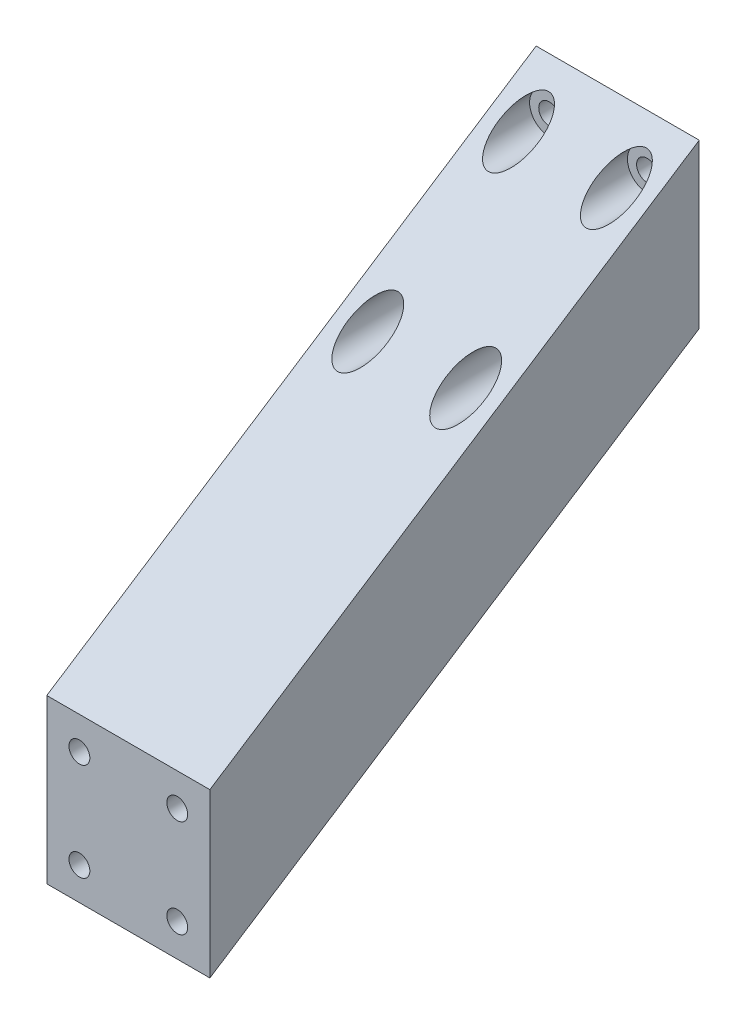
from build123d import *

# Parameters (mm, degrees)
BOSS_EXTRUDE1_DEPTH = 25
CUT_EXTRUDE7_REACH  = 97.856
CUT_EXTRUDE7_START  = -3
SKETCH3_R           = 3
SKETCH3_R_2         = 1.6
CUT_EXTRUDE8_REACH  = 94.856
SKETCH3_3_R         = 1.6
CUT_EXTRUDE9_REACH  = 97.856
CUT_EXTRUDE9_START  = -3
SKETCH4_R           = 3
SKETCH4_R_2         = 1.6
CUT_EXTRUDE10_REACH = 94.856
SKETCH4_2_R         = 1.6


with BuildPart() as part:
    # Sketch1 → Boss-Extrude1 (new body)
    with BuildSketch(Plane(origin=(0, 0, 0), x_dir=(0, 0, -1), z_dir=(1, 0, 0))):
        Polygon((0, 0), (-75, -48.70556949), (-75, -23.70556949), (0, 25), align=None)
    extrude(amount=BOSS_EXTRUDE1_DEPTH)

    # Sketch3 → Cut-Extrude7 (cut, up to next)
    with BuildSketch(Plane(origin=(0, 0, 0), x_dir=(-1, 0, 0), z_dir=(0, 0, -1)).offset(CUT_EXTRUDE7_START), mode=Mode.PRIVATE) as cut_extrude7_sk1:
        with Locations((-20, 20)):
            Circle(SKETCH3_R)
        with Locations((-20, 20)):
            Circle(SKETCH3_R_2, mode=Mode.SUBTRACT)
    cut_extrude7_tool1 = extrude(cut_extrude7_sk1.sketch, amount=-CUT_EXTRUDE7_REACH, mode=Mode.PRIVATE) & part.part
    # Sketch3 → Cut-Extrude7 (cut, up to next)
    with BuildSketch(Plane(origin=(0, 0, 0), x_dir=(-1, 0, 0), z_dir=(0, 0, -1)).offset(CUT_EXTRUDE7_START), mode=Mode.PRIVATE) as cut_extrude7_sk2:
        with Locations((-20, 5)):
            Circle(SKETCH3_R)
        with Locations((-20, 5)):
            Circle(SKETCH3_R_2, mode=Mode.SUBTRACT)
    cut_extrude7_tool2 = extrude(cut_extrude7_sk2.sketch, amount=-CUT_EXTRUDE7_REACH, mode=Mode.PRIVATE) & part.part
    # Sketch3 → Cut-Extrude7 (cut, up to next)
    with BuildSketch(Plane(origin=(0, 0, 0), x_dir=(-1, 0, 0), z_dir=(0, 0, -1)).offset(CUT_EXTRUDE7_START), mode=Mode.PRIVATE) as cut_extrude7_sk3:
        with Locations((-5, 5)):
            Circle(SKETCH3_R)
        with Locations((-5, 5)):
            Circle(SKETCH3_R_2, mode=Mode.SUBTRACT)
    cut_extrude7_tool3 = extrude(cut_extrude7_sk3.sketch, amount=-CUT_EXTRUDE7_REACH, mode=Mode.PRIVATE) & part.part
    # Sketch3 → Cut-Extrude7 (cut, up to next)
    with BuildSketch(Plane(origin=(0, 0, 0), x_dir=(-1, 0, 0), z_dir=(0, 0, -1)).offset(CUT_EXTRUDE7_START), mode=Mode.PRIVATE) as cut_extrude7_sk4:
        with Locations((-5, 20)):
            Circle(SKETCH3_R)
        with Locations((-5, 20)):
            Circle(SKETCH3_R_2, mode=Mode.SUBTRACT)
    cut_extrude7_tool4 = extrude(cut_extrude7_sk4.sketch, amount=-CUT_EXTRUDE7_REACH, mode=Mode.PRIVATE) & part.part
    add(cut_extrude7_tool1.solids().sort_by_distance((22.915147, 20, 3))[0], mode=Mode.SUBTRACT)
    add(cut_extrude7_tool2.solids().sort_by_distance((22.915147, 5, 3))[0], mode=Mode.SUBTRACT)
    add(cut_extrude7_tool3.solids().sort_by_distance((7.915147, 5, 3))[0], mode=Mode.SUBTRACT)
    add(cut_extrude7_tool4.solids().sort_by_distance((7.915147, 20, 3))[0], mode=Mode.SUBTRACT)

    # Sketch3_3 → Cut-Extrude8 (cut, up to next)
    with BuildSketch(Plane(origin=(0, 0, 0), x_dir=(-1, 0, 0), z_dir=(0, 0, -1)), mode=Mode.PRIVATE) as cut_extrude8_sk1:
        with Locations((-20, 20)):
            Circle(SKETCH3_3_R)
    cut_extrude8_tool1 = extrude(cut_extrude8_sk1.sketch, amount=-CUT_EXTRUDE8_REACH, mode=Mode.PRIVATE) & part.part
    # Sketch3_3 → Cut-Extrude8 (cut, up to next)
    with BuildSketch(Plane(origin=(0, 0, 0), x_dir=(-1, 0, 0), z_dir=(0, 0, -1)), mode=Mode.PRIVATE) as cut_extrude8_sk2:
        with Locations((-20, 5)):
            Circle(SKETCH3_3_R)
    cut_extrude8_tool2 = extrude(cut_extrude8_sk2.sketch, amount=-CUT_EXTRUDE8_REACH, mode=Mode.PRIVATE) & part.part
    # Sketch3_3 → Cut-Extrude8 (cut, up to next)
    with BuildSketch(Plane(origin=(0, 0, 0), x_dir=(-1, 0, 0), z_dir=(0, 0, -1)), mode=Mode.PRIVATE) as cut_extrude8_sk3:
        with Locations((-5, 5)):
            Circle(SKETCH3_3_R)
    cut_extrude8_tool3 = extrude(cut_extrude8_sk3.sketch, amount=-CUT_EXTRUDE8_REACH, mode=Mode.PRIVATE) & part.part
    # Sketch3_3 → Cut-Extrude8 (cut, up to next)
    with BuildSketch(Plane(origin=(0, 0, 0), x_dir=(-1, 0, 0), z_dir=(0, 0, -1)), mode=Mode.PRIVATE) as cut_extrude8_sk4:
        with Locations((-5, 20)):
            Circle(SKETCH3_3_R)
    cut_extrude8_tool4 = extrude(cut_extrude8_sk4.sketch, amount=-CUT_EXTRUDE8_REACH, mode=Mode.PRIVATE) & part.part
    add(cut_extrude8_tool1.solids().sort_by_distance((20, 20, 0))[0], mode=Mode.SUBTRACT)
    add(cut_extrude8_tool2.solids().sort_by_distance((20, 5, 0))[0], mode=Mode.SUBTRACT)
    add(cut_extrude8_tool3.solids().sort_by_distance((5, 5, 0))[0], mode=Mode.SUBTRACT)
    add(cut_extrude8_tool4.solids().sort_by_distance((5, 20, 0))[0], mode=Mode.SUBTRACT)

    # Sketch4 → Cut-Extrude9 (cut, up to next)
    with BuildSketch(Plane.XY.offset(75).offset(CUT_EXTRUDE9_START), mode=Mode.PRIVATE) as cut_extrude9_sk1:
        with Locations((5, -28.70556949)):
            Circle(SKETCH4_R)
        with Locations((5, -28.70556949)):
            Circle(SKETCH4_R_2, mode=Mode.SUBTRACT)
    cut_extrude9_tool1 = extrude(cut_extrude9_sk1.sketch, amount=-CUT_EXTRUDE9_REACH, mode=Mode.PRIVATE) & part.part
    # Sketch4 → Cut-Extrude9 (cut, up to next)
    with BuildSketch(Plane.XY.offset(75).offset(CUT_EXTRUDE9_START), mode=Mode.PRIVATE) as cut_extrude9_sk2:
        with Locations((5, -43.70556949)):
            Circle(SKETCH4_R)
        with Locations((5, -43.70556949)):
            Circle(SKETCH4_R_2, mode=Mode.SUBTRACT)
    cut_extrude9_tool2 = extrude(cut_extrude9_sk2.sketch, amount=-CUT_EXTRUDE9_REACH, mode=Mode.PRIVATE) & part.part
    # Sketch4 → Cut-Extrude9 (cut, up to next)
    with BuildSketch(Plane.XY.offset(75).offset(CUT_EXTRUDE9_START), mode=Mode.PRIVATE) as cut_extrude9_sk3:
        with Locations((20, -43.70556949)):
            Circle(SKETCH4_R)
        with Locations((20, -43.70556949)):
            Circle(SKETCH4_R_2, mode=Mode.SUBTRACT)
    cut_extrude9_tool3 = extrude(cut_extrude9_sk3.sketch, amount=-CUT_EXTRUDE9_REACH, mode=Mode.PRIVATE) & part.part
    # Sketch4 → Cut-Extrude9 (cut, up to next)
    with BuildSketch(Plane.XY.offset(75).offset(CUT_EXTRUDE9_START), mode=Mode.PRIVATE) as cut_extrude9_sk4:
        with Locations((20, -28.70556949)):
            Circle(SKETCH4_R)
        with Locations((20, -28.70556949)):
            Circle(SKETCH4_R_2, mode=Mode.SUBTRACT)
    cut_extrude9_tool4 = extrude(cut_extrude9_sk4.sketch, amount=-CUT_EXTRUDE9_REACH, mode=Mode.PRIVATE) & part.part
    add(cut_extrude9_tool1.solids().sort_by_distance((2.084853, -28.705569, 72))[0], mode=Mode.SUBTRACT)
    add(cut_extrude9_tool2.solids().sort_by_distance((2.084853, -43.705569, 72))[0], mode=Mode.SUBTRACT)
    add(cut_extrude9_tool3.solids().sort_by_distance((17.084853, -43.705569, 72))[0], mode=Mode.SUBTRACT)
    add(cut_extrude9_tool4.solids().sort_by_distance((17.084853, -28.705569, 72))[0], mode=Mode.SUBTRACT)

    # Sketch4_2 → Cut-Extrude10 (cut, up to next)
    with BuildSketch(Plane.XY.offset(75), mode=Mode.PRIVATE) as cut_extrude10_sk1:
        with Locations((5, -28.70556949)):
            Circle(SKETCH4_2_R)
    cut_extrude10_tool1 = extrude(cut_extrude10_sk1.sketch, amount=-CUT_EXTRUDE10_REACH, mode=Mode.PRIVATE) & part.part
    # Sketch4_2 → Cut-Extrude10 (cut, up to next)
    with BuildSketch(Plane.XY.offset(75), mode=Mode.PRIVATE) as cut_extrude10_sk2:
        with Locations((5, -43.70556949)):
            Circle(SKETCH4_2_R)
    cut_extrude10_tool2 = extrude(cut_extrude10_sk2.sketch, amount=-CUT_EXTRUDE10_REACH, mode=Mode.PRIVATE) & part.part
    # Sketch4_2 → Cut-Extrude10 (cut, up to next)
    with BuildSketch(Plane.XY.offset(75), mode=Mode.PRIVATE) as cut_extrude10_sk3:
        with Locations((20, -43.70556949)):
            Circle(SKETCH4_2_R)
    cut_extrude10_tool3 = extrude(cut_extrude10_sk3.sketch, amount=-CUT_EXTRUDE10_REACH, mode=Mode.PRIVATE) & part.part
    # Sketch4_2 → Cut-Extrude10 (cut, up to next)
    with BuildSketch(Plane.XY.offset(75), mode=Mode.PRIVATE) as cut_extrude10_sk4:
        with Locations((20, -28.70556949)):
            Circle(SKETCH4_2_R)
    cut_extrude10_tool4 = extrude(cut_extrude10_sk4.sketch, amount=-CUT_EXTRUDE10_REACH, mode=Mode.PRIVATE) & part.part
    add(cut_extrude10_tool1.solids().sort_by_distance((5, -28.705569, 75))[0], mode=Mode.SUBTRACT)
    add(cut_extrude10_tool2.solids().sort_by_distance((5, -43.705569, 75))[0], mode=Mode.SUBTRACT)
    add(cut_extrude10_tool3.solids().sort_by_distance((20, -43.705569, 75))[0], mode=Mode.SUBTRACT)
    add(cut_extrude10_tool4.solids().sort_by_distance((20, -28.705569, 75))[0], mode=Mode.SUBTRACT)


solid = part.part
